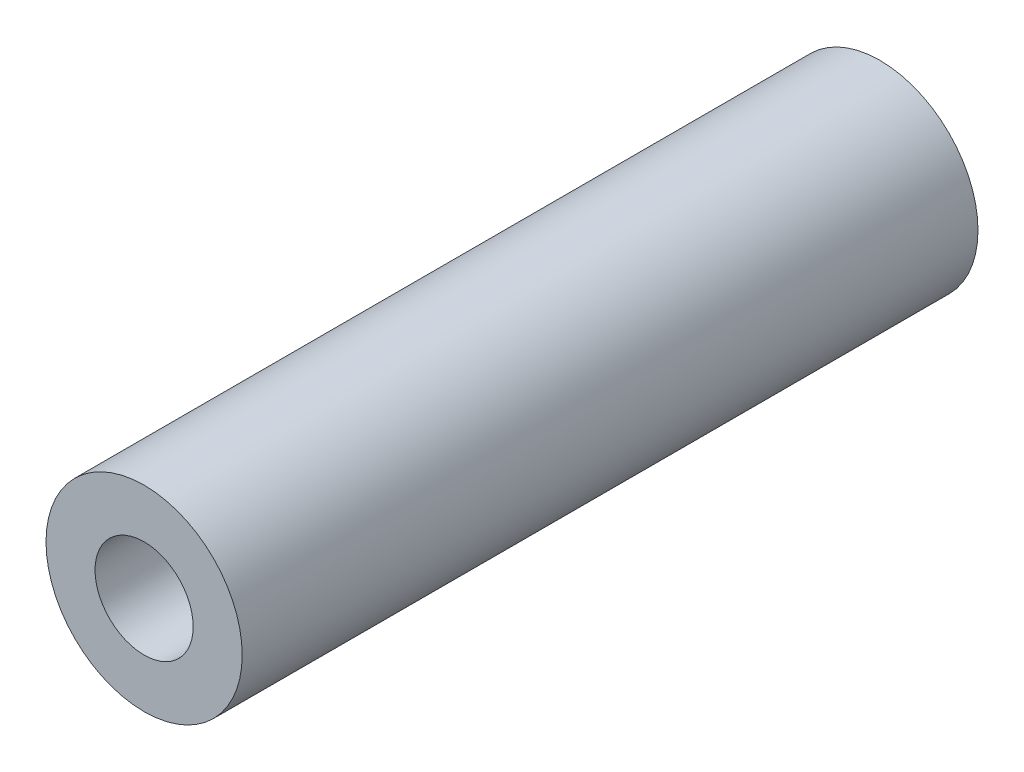
from build123d import *

# Parameters (mm, degrees)
SKETCH1_R           = 4
BOSS_EXTRUDE1_DEPTH = 30
SKETCH2_R           = 2
CUT_EXTRUDE1_DEPTH  = 31


with BuildPart() as part:
    # Sketch1 → Boss-Extrude1 (new body)
    with BuildSketch(Plane.XY):
        Circle(SKETCH1_R)
    extrude(amount=BOSS_EXTRUDE1_DEPTH)

    # Sketch2 → Cut-Extrude1 (cut, through all)
    with BuildSketch(Plane.XY.offset(30)):
        Circle(SKETCH2_R)
    extrude(amount=-CUT_EXTRUDE1_DEPTH, mode=Mode.SUBTRACT)


solid = part.part
